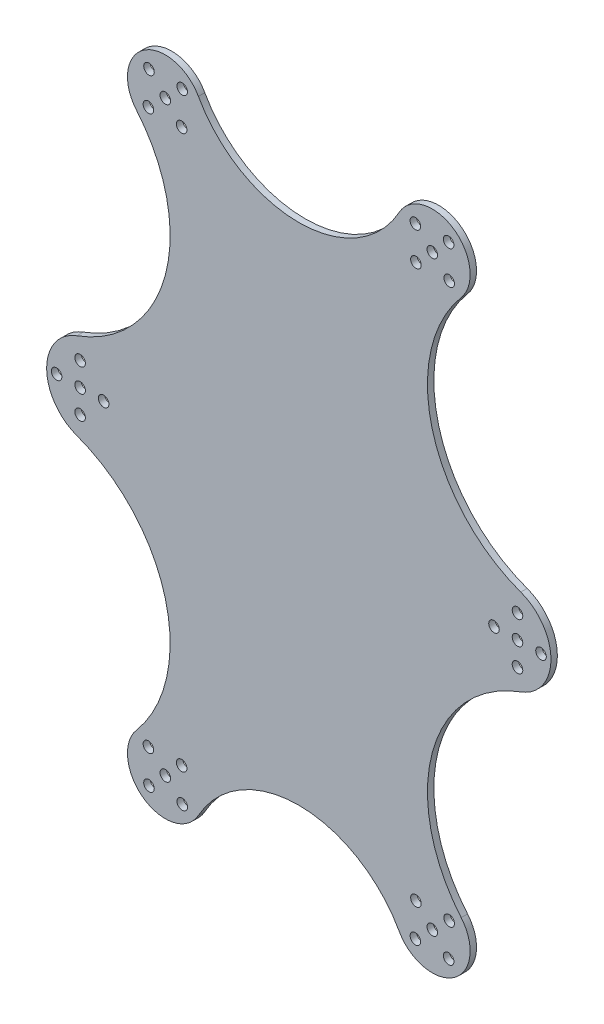
from build123d import *

# Parameters (mm, degrees)
SKETCH_1_R      = 1.65
EXTRUDE_1_DEPTH = 2


with BuildPart() as part:
    # 草图1 → 凸台-拉伸1 (new body)
    with BuildSketch(Plane.XY):
        with BuildLine():
            ThreePointArc((3.478825803, 1.140085793), (31.160613474, 31.487300358), (22.098035111, 71.551055473))
            ThreePointArc((22.098035111, 71.551055473), (22.097226992, 71.552008754), (22.096419384, 71.552962467))
            ThreePointArc((22.096419384, 71.552962467), (24.398037137, 88.92818843), (41.467336112, 84.948872654))
            ThreePointArc((41.467336112, 84.948872654), (72.85197551, 66.494603701), (104.236614907, 84.948872654))
            ThreePointArc((104.236614907, 84.948872654), (121.305913882, 88.92818843), (123.607531636, 71.552962467))
            ThreePointArc((123.607531636, 71.552962467), (123.606724028, 71.552008754), (123.605915909, 71.551055473))
            ThreePointArc((123.605915909, 71.551055473), (114.543337545, 31.487300358), (142.225125217, 1.140085793))
            ThreePointArc((142.225125217, 1.140085793), (151.67398287, -12.372302839), (142.225125217, -25.884691472))
            ThreePointArc((142.225125217, -25.884691472), (114.543337545, -56.231906037), (123.605915909, -96.295661152))
            ThreePointArc((123.605915909, -96.295661152), (123.606724028, -96.296614433), (123.607531636, -96.297568146))
            ThreePointArc((123.607531636, -96.297568146), (121.305913882, -113.672794108), (104.236614907, -109.693478333))
            ThreePointArc((104.236614907, -109.693478333), (72.85197551, -91.23920938), (41.467336112, -109.693478333))
            ThreePointArc((41.467336112, -109.693478333), (24.398037137, -113.672794108), (22.096419384, -96.297568146))
            ThreePointArc((22.096419384, -96.297568146), (22.097226992, -96.296614433), (22.098035111, -96.295661152))
            ThreePointArc((22.098035111, -96.295661152), (31.160613474, -56.231906037), (3.478825803, -25.884691472))
            ThreePointArc((3.478825803, -25.884691472), (-5.97003185, -12.372302839), (3.478825803, 1.140085793))
        make_face()
        with Locations((11.842583941, -12.372302839)):
            Circle(SKETCH_1_R, mode=Mode.SUBTRACT)
        with Locations((119.681841833, 84.617416188)):
            Circle(SKETCH_1_R, mode=Mode.SUBTRACT)
        with Locations((36.414995742, 84.436007679)):
            Circle(SKETCH_1_R, mode=Mode.SUBTRACT)
        with Locations((36.233587233, 74.043121123)):
            Circle(SKETCH_1_R, mode=Mode.SUBTRACT)
        with Locations((4.492583941, -19.722302839)):
            Circle(SKETCH_1_R, mode=Mode.SUBTRACT)
        with Locations((114.57610281, 79.330268656)):
            Circle(SKETCH_1_R, mode=Mode.SUBTRACT)
        with Locations((119.863250342, 74.224529633)):
            Circle(SKETCH_1_R, mode=Mode.SUBTRACT)
        with Locations((141.211367078, -5.022302839)):
            Circle(SKETCH_1_R, mode=Mode.SUBTRACT)
        with Locations((109.470363787, 74.043121123)):
            Circle(SKETCH_1_R, mode=Mode.SUBTRACT)
        with Locations((148.561367078, -12.372302839)):
            Circle(SKETCH_1_R, mode=Mode.SUBTRACT)
        with Locations((141.211367078, -19.722302839)):
            Circle(SKETCH_1_R, mode=Mode.SUBTRACT)
        with Locations((141.211367078, -12.372302839)):
            Circle(SKETCH_1_R, mode=Mode.SUBTRACT)
        with Locations((109.288955277, 84.436007679)):
            Circle(SKETCH_1_R, mode=Mode.SUBTRACT)
        with Locations((133.861367078, -12.372302839)):
            Circle(SKETCH_1_R, mode=Mode.SUBTRACT)
        with Locations((4.492583941, -5.022302839)):
            Circle(SKETCH_1_R, mode=Mode.SUBTRACT)
        with Locations((26.022109187, -109.362021867)):
            Circle(SKETCH_1_R, mode=Mode.SUBTRACT)
        with Locations((31.12784821, -104.074874334)):
            Circle(SKETCH_1_R, mode=Mode.SUBTRACT)
        with Locations((25.840700677, -98.969135312)):
            Circle(SKETCH_1_R, mode=Mode.SUBTRACT)
        with Locations((25.840700677, 74.224529633)):
            Circle(SKETCH_1_R, mode=Mode.SUBTRACT)
        with Locations((31.12784821, 79.330268656)):
            Circle(SKETCH_1_R, mode=Mode.SUBTRACT)
        with Locations((26.022109187, 84.617416188)):
            Circle(SKETCH_1_R, mode=Mode.SUBTRACT)
        with Locations((109.288955277, -109.180613357)):
            Circle(SKETCH_1_R, mode=Mode.SUBTRACT)
        with Locations((109.470363787, -98.787726802)):
            Circle(SKETCH_1_R, mode=Mode.SUBTRACT)
        with Locations((119.863250342, -98.969135312)):
            Circle(SKETCH_1_R, mode=Mode.SUBTRACT)
        with Locations((114.57610281, -104.074874334)):
            Circle(SKETCH_1_R, mode=Mode.SUBTRACT)
        with Locations((36.233587233, -98.787726802)):
            Circle(SKETCH_1_R, mode=Mode.SUBTRACT)
        with Locations((36.414995742, -109.180613357)):
            Circle(SKETCH_1_R, mode=Mode.SUBTRACT)
        with Locations((119.681841833, -109.362021867)):
            Circle(SKETCH_1_R, mode=Mode.SUBTRACT)
        with Locations((-2.857416059, -12.372302839)):
            Circle(SKETCH_1_R, mode=Mode.SUBTRACT)
        with Locations((4.492583941, -12.372302839)):
            Circle(SKETCH_1_R, mode=Mode.SUBTRACT)
    extrude(amount=EXTRUDE_1_DEPTH)


solid = part.part
